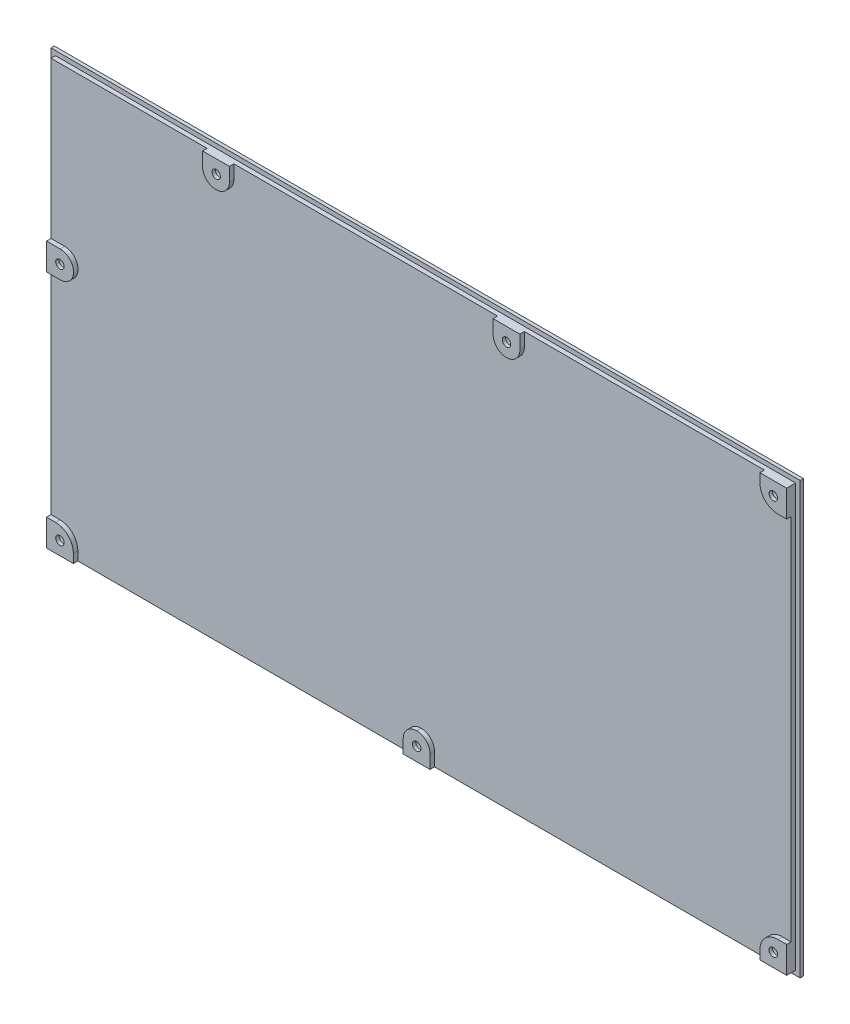
from build123d import *

# Parameters (mm, degrees)
SKETCH1_W           = 335.5
SKETCH1_H           = 193
BOSS_EXTRUDE1_DEPTH = 1.5
BOSS_EXTRUDE2_DEPTH = 2
BOSS_EXTRUDE3_DEPTH = 4
SKETCH5_R           = 4
CUT_EXTRUDE1_DEPTH  = 4
SKETCH6_R           = 1.9
CUT_EXTRUDE2_DEPTH  = 14


with BuildPart() as part:
    # Sketch1 → Boss-Extrude1 (new body)
    with BuildSketch(Plane.XY):
        Rectangle(SKETCH1_W, SKETCH1_H)
    extrude(amount=BOSS_EXTRUDE1_DEPTH)

    # Sketch2 → Boss-Extrude2 (add)
    with BuildSketch(Plane.XY.offset(1.5)):
        with BuildLine():
            Line((-153.75, -90.5), (-153.75, -94.5))
            Line((-153.75, -94.5), (-6, -94.5))
            Line((-6, -94.5), (-6, -88.4))
            ThreePointArc((-6, -88.4), (-4.271930009, -84.228069991), (-0.1, -82.5))
            Line((-0.1, -82.5), (0.1, -82.5))
            ThreePointArc((0.1, -82.5), (4.271930009, -84.228069991), (6, -88.4))
            Line((6, -88.4), (6, -94.5))
            Line((6, -94.5), (153.75, -94.5))
            Line((153.75, -94.5), (153.75, -90.5))
            ThreePointArc((153.75, -90.5), (156.093145751, -84.843145751), (161.75, -82.5))
            Line((161.75, -82.5), (165.75, -82.5))
            Line((165.75, -82.5), (165.75, 82.5))
            Line((165.75, 82.5), (161.75, 82.5))
            ThreePointArc((161.75, 82.5), (156.093145751, 84.843145751), (153.75, 90.5))
            Line((153.75, 90.5), (153.75, 94.5))
            Line((153.75, 94.5), (6, 94.5))
            Line((6, 94.5), (-6, 94.5))
            Line((-6, 94.5), (-153.75, 94.5))
            Line((-153.75, 94.5), (-165.75, 94.5))
            Line((-165.75, 94.5), (-165.75, 82.5))
            Line((-165.75, 82.5), (-165.75, -82.5))
            Line((-165.75, -82.5), (-161.75, -82.5))
            ThreePointArc((-161.75, -82.5), (-156.093145751, -84.843145751), (-153.75, -90.5))
        make_face()
    extrude(amount=BOSS_EXTRUDE2_DEPTH)

    # Sketch4 → Boss-Extrude3 (add)
    with BuildSketch(Plane.XY.offset(1.5)):
        with BuildLine():
            Line((-165.75, -82.5), (-165.75, -94.5))
            Line((-165.75, -94.5), (-153.75, -94.5))
            Line((-153.75, -94.5), (-153.75, -90.5))
            ThreePointArc((-153.75, -90.5), (-156.093145751, -84.843145751), (-161.75, -82.5))
            Line((-161.75, -82.5), (-165.75, -82.5))
        make_face()
        with BuildLine():
            Line((-6, -94.5), (6, -94.5))
            Line((6, -94.5), (6, -88.4))
            ThreePointArc((6, -88.4), (4.271930009, -84.228069991), (0.1, -82.5))
            Line((0.1, -82.5), (-0.1, -82.5))
            ThreePointArc((-0.1, -82.5), (-4.271930009, -84.228069991), (-6, -88.4))
            Line((-6, -88.4), (-6, -94.5))
        make_face()
        with BuildLine():
            Line((153.75, -94.5), (165.75, -94.5))
            Line((165.75, -94.5), (165.75, -82.5))
            Line((165.75, -82.5), (161.75, -82.5))
            ThreePointArc((161.75, -82.5), (156.093145751, -84.843145751), (153.75, -90.5))
            Line((153.75, -90.5), (153.75, -94.5))
        make_face()
        with BuildLine():
            Line((165.75, 94.5), (165.75, 82.5))
            Line((165.75, 82.5), (161.75, 82.5))
            ThreePointArc((161.75, 82.5), (156.093145751, 84.843145751), (153.75, 90.5))
            Line((153.75, 90.5), (153.75, 94.5))
            Line((153.75, 94.5), (165.75, 94.5))
        make_face()
        with BuildLine():
            Line((-165.75, 24.6), (-165.75, 12.6))
            Line((-165.75, 12.6), (-159.65, 12.6))
            ThreePointArc((-159.65, 12.6), (-153.65, 18.6), (-159.65, 24.6))
            Line((-159.65, 24.6), (-165.75, 24.6))
        make_face()
        with BuildLine():
            Line((-83.85, 94.5), (-95.85, 94.5))
            Line((-95.85, 94.5), (-95.85, 88.4))
            ThreePointArc((-95.85, 88.4), (-94.121930009, 84.228069991), (-89.95, 82.5))
            Line((-89.95, 82.5), (-89.75, 82.5))
            ThreePointArc((-89.75, 82.5), (-85.578069991, 84.228069991), (-83.85, 88.4))
            Line((-83.85, 88.4), (-83.85, 94.5))
        make_face()
        with BuildLine():
            Line((46.25, 94.5), (34.25, 94.5))
            Line((34.25, 94.5), (34.25, 88.4))
            ThreePointArc((34.25, 88.4), (40.25, 82.4), (46.25, 88.4))
            Line((46.25, 88.4), (46.25, 94.5))
        make_face()
    extrude(amount=BOSS_EXTRUDE3_DEPTH)

    # Sketch5 → Cut-Extrude1 (cut)
    with BuildSketch(Plane(origin=(0, 0, 0), x_dir=(-1, 0, 0), z_dir=(0, 0, -1))):
        with Locations((-159.75, 88.5)):
            Circle(SKETCH5_R)
        with Locations((0, -88.5)):
            Circle(SKETCH5_R)
        with Locations((159.75, -88.5)):
            Circle(SKETCH5_R)
        with Locations((-159.75, -88.5)):
            Circle(SKETCH5_R)
        with Locations((89.75, 88.5)):
            Circle(SKETCH5_R)
        with Locations((-40.25, 88.4)):
            Circle(SKETCH5_R)
        with Locations((159.75, 18.6)):
            Circle(SKETCH5_R)
    extrude(amount=-CUT_EXTRUDE1_DEPTH, mode=Mode.SUBTRACT)

    # Sketch6 → Cut-Extrude2 (cut)
    with BuildSketch(Plane(origin=(0, 0, 0), x_dir=(-1, 0, 0), z_dir=(0, 0, -1))):
        with Locations((-159.75, -88.5)):
            Circle(SKETCH6_R)
        with Locations((0, -88.5)):
            Circle(SKETCH6_R)
        with Locations((159.75, -88.5)):
            Circle(SKETCH6_R)
        with Locations((-159.75, 88.5)):
            Circle(SKETCH6_R)
        with Locations((89.75, 88.5)):
            Circle(SKETCH6_R)
        with Locations((159.75, 18.6)):
            Circle(SKETCH6_R)
        with Locations((-40.25, 88.4)):
            Circle(SKETCH6_R)
    extrude(amount=-CUT_EXTRUDE2_DEPTH, mode=Mode.SUBTRACT)


solid = part.part
